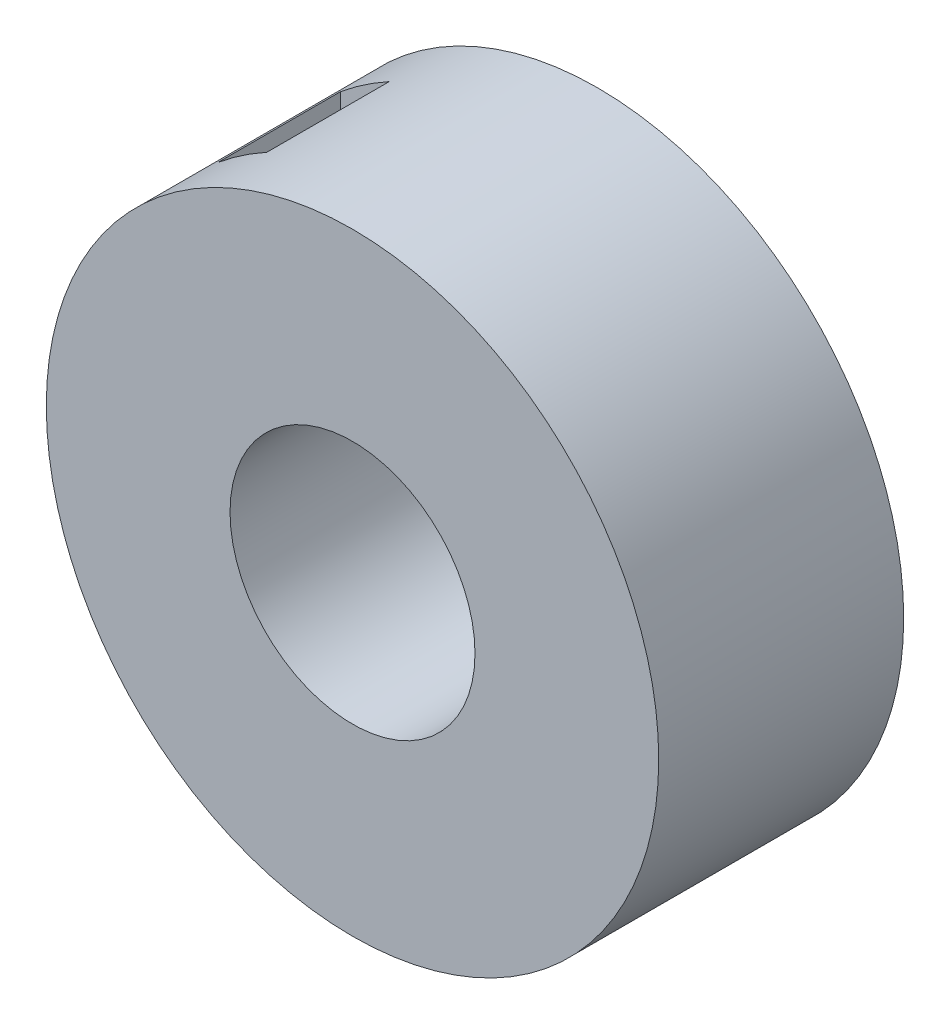
from build123d import *

# Parameters (mm, degrees)
SALIENTE_EXTRUIR1_DEPTH      = 0.25
SALIENTE_EXTRUIR1_DEPTH_BACK = 0.25
CROQUIS1_R                   = 0.625
CROQUIS1_R_2                 = 0.25
CORTAR_EXTRUIR1_DEPTH        = 0.125
CORTAR_EXTRUIR1_DEPTH_BACK   = 0.125


with BuildPart() as part:
    # Croquis1 → Saliente-Extruir1 (new, two sides: drawn at the far end of the back side and taken through both)
    with BuildSketch(Plane.XY.offset(-SALIENTE_EXTRUIR1_DEPTH_BACK)):
        Circle(CROQUIS1_R)
        Circle(CROQUIS1_R_2, mode=Mode.SUBTRACT)
    extrude(amount=SALIENTE_EXTRUIR1_DEPTH + SALIENTE_EXTRUIR1_DEPTH_BACK)

    # Croquis2 → Cortar-Extruir1 (cut, two sides: drawn at the far end of the back side and taken through both)
    with BuildSketch(Plane.XY.offset(-CORTAR_EXTRUIR1_DEPTH_BACK)):
        with BuildLine():
            Line((-0.3, -0.548292805), (-0.3, 0.548292805))
            ThreePointArc((-0.3, 0.548292805), (-0.35165038, 0.516688504), (-0.4, 0.480234318))
            Line((-0.4, 0.480234318), (-0.4, -0.480234318))
            ThreePointArc((-0.4, -0.480234318), (-0.35165038, -0.516688504), (-0.3, -0.548292805))
        make_face()
    extrude(amount=CORTAR_EXTRUIR1_DEPTH + CORTAR_EXTRUIR1_DEPTH_BACK, mode=Mode.SUBTRACT)


solid = part.part
